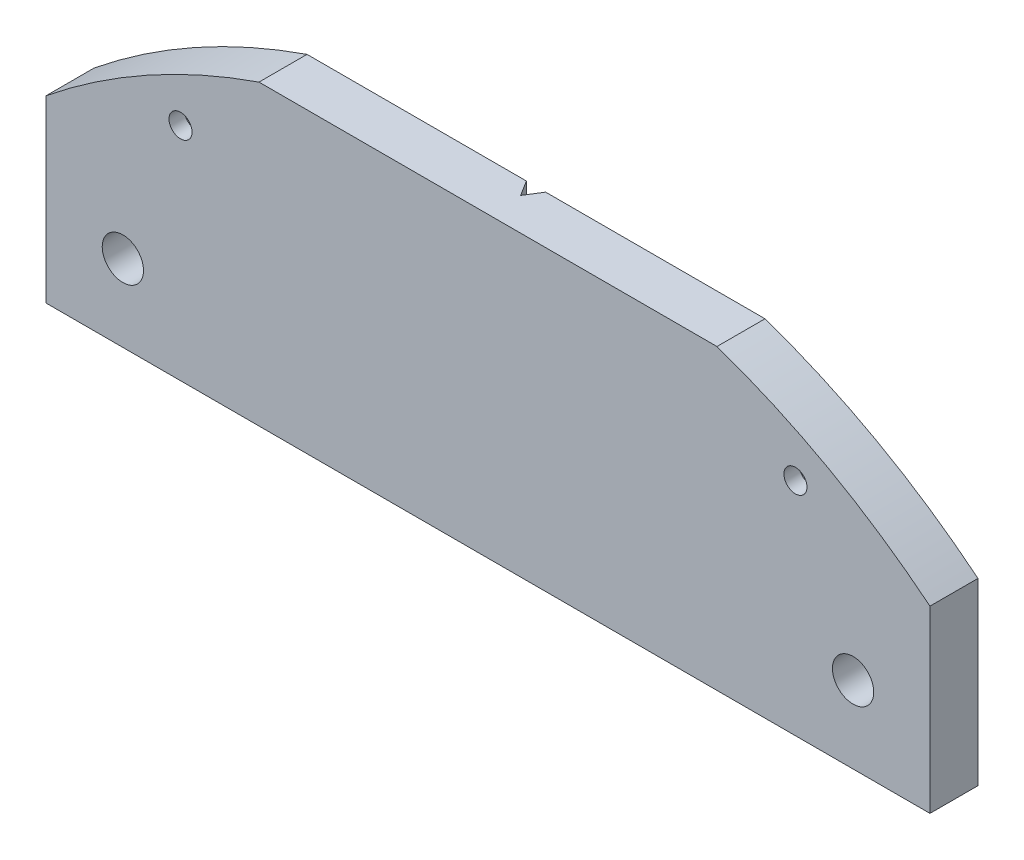
from build123d import *

# Parameters (mm, degrees)
SKETCH3_W           = 92
SKETCH3_H           = 31
BOSS_EXTRUDE2_DEPTH = 5
SKETCH4_R           = 103
SKETCH4_R_2         = 73
CUT_EXTRUDE1_DEPTH  = 6
SKETCH5_R           = 2.15
CUT_EXTRUDE2_DEPTH  = 6
CUT_EXTRUDE4_DEPTH  = 32
SKETCH8_R           = 1.2
CUT_EXTRUDE5_DEPTH  = 6
SKETCH9_R           = 2.1
CUT_EXTRUDE6_DEPTH  = 3.4


with BuildPart() as part:
    # Sketch3 → Boss-Extrude2 (new body)
    with BuildSketch(Plane.XY):
        Rectangle(SKETCH3_W, SKETCH3_H)
    extrude(amount=BOSS_EXTRUDE2_DEPTH)

    # Sketch4 → Cut-Extrude1 (cut, through all)
    with BuildSketch(Plane.XY.offset(5)):
        with Locations((0, -53.5)):
            Circle(SKETCH4_R)
        with Locations((0, -53.5)):
            Circle(SKETCH4_R_2, mode=Mode.SUBTRACT)
    extrude(amount=-CUT_EXTRUDE1_DEPTH, mode=Mode.SUBTRACT)

    # Sketch5 → Cut-Extrude2 (cut, through all)
    with BuildSketch(Plane.XY.offset(5)):
        with Locations((38, -7.5)):
            Circle(SKETCH5_R)
        with Locations((-38, -7.5)):
            Circle(SKETCH5_R)
    extrude(amount=-CUT_EXTRUDE2_DEPTH, mode=Mode.SUBTRACT)

    # Sketch7 → Cut-Extrude4 (cut, through all)
    with BuildSketch(Plane.XZ.offset(15.5)):
        Polygon((-1, 0), (0, 1.6), (1, 0), align=None)
    extrude(amount=-CUT_EXTRUDE4_DEPTH, mode=Mode.SUBTRACT)

    # Sketch8 → Cut-Extrude5 (cut, through all)
    with BuildSketch(Plane.XY.offset(5)):
        with Locations((-32, 7.5)):
            Circle(SKETCH8_R)
        with Locations((32, 7.5)):
            Circle(SKETCH8_R)
    extrude(amount=-CUT_EXTRUDE5_DEPTH, mode=Mode.SUBTRACT)

    # Sketch9 → Cut-Extrude6 (cut)
    with BuildSketch(Plane(origin=(0, 0, 0), x_dir=(-1, 0, 0), z_dir=(0, 0, -1))):
        with Locations((32, 7.5)):
            Circle(SKETCH9_R)
        with Locations((-32, 7.5)):
            Circle(SKETCH9_R)
    extrude(amount=-CUT_EXTRUDE6_DEPTH, mode=Mode.SUBTRACT)


solid = part.part
